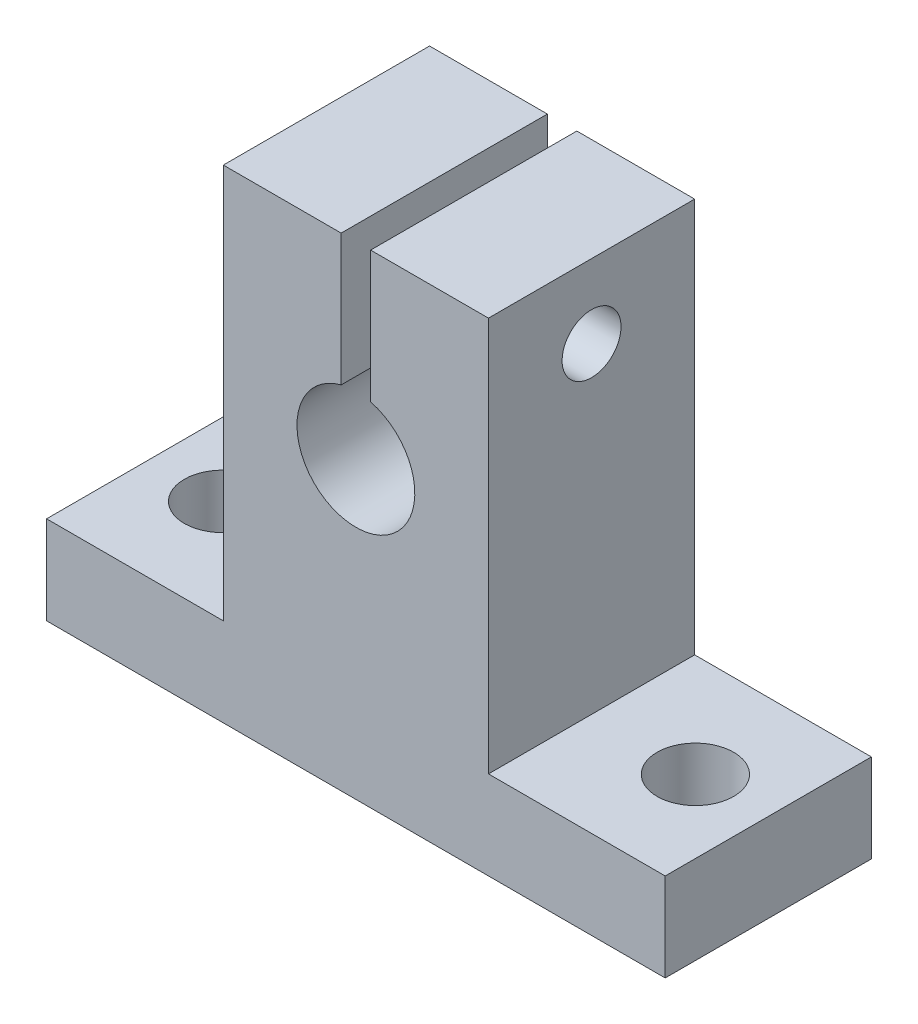
from build123d import *

# Parameters (mm, degrees)
SALIENTE_EXTRUIR1_DEPTH = 14
CROQUIS2_R              = 2.6
CORTAR_EXTRUIR1_DEPTH   = 14
CORTAR_EXTRUIR2_DEPTH   = 42.386471219
CROQUIS4_R              = 2
CORTAR_EXTRUIR3_DEPTH   = 47.603004195


with BuildPart() as part:
    # Croquis1 → Saliente-Extruir1 (new body)
    with BuildSketch(Plane.XY):
        Polygon((-9, 6), (-9, 32.8), (9, 32.8), (9, 6), (21, 6), (21, 0), (-21, 0), (-21, 6), align=None)
    extrude(amount=SALIENTE_EXTRUIR1_DEPTH)

    # Croquis2 → Cortar-Extruir1 (cut)
    with BuildSketch(Plane(origin=(0, 6, 0), x_dir=(1, 0, 0), z_dir=(0, 1, 0))):
        with Locations((-16.05, -7)):
            Circle(CROQUIS2_R)
        with Locations((16.05, -7)):
            Circle(CROQUIS2_R)
    extrude(amount=-CORTAR_EXTRUIR1_DEPTH, mode=Mode.SUBTRACT)

    # Croquis3 → Cortar-Extruir2 (cut, through all)
    with BuildSketch(Plane.XY.offset(14)):
        with BuildLine():
            Line((-1, 23.872983346), (-1, 32.8))
            Line((-1, 32.8), (1, 32.8))
            Line((1, 32.8), (1, 23.872983346))
            ThreePointArc((1, 23.872983346), (0, 16), (-1, 23.872983346))
        make_face()
    extrude(amount=-CORTAR_EXTRUIR2_DEPTH, mode=Mode.SUBTRACT)

    # Croquis4 → Cortar-Extruir3 (cut, through all)
    with BuildSketch(Plane.ZY.offset(9)):
        with Locations((7, 27.8)):
            Circle(CROQUIS4_R)
    extrude(amount=-CORTAR_EXTRUIR3_DEPTH, mode=Mode.SUBTRACT)


solid = part.part
